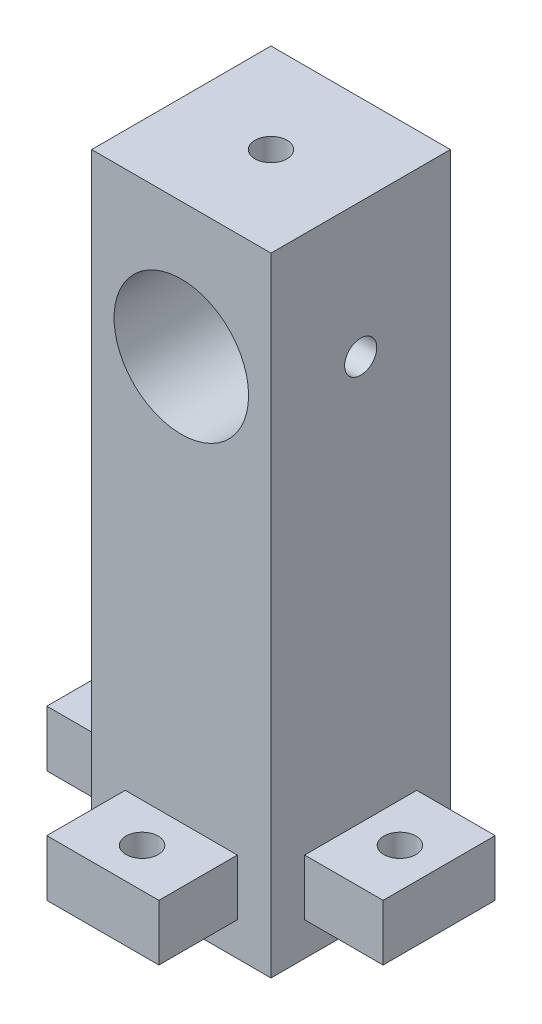
from build123d import *

# Parameters (mm, degrees)
CROQUIS1_W              = 16
CROQUIS1_H              = 16
SALIENTE_EXTRUIR1_DEPTH = 56
CORTAR_EXTRUIR1_REACH   = 18
CROQUIS2_R              = 6
CROQUIS3_R              = 1.435
CORTAR_EXTRUIR2_DEPTH   = 16
CORTAR_EXTRUIR3_REACH   = 58
CROQUIS4_R              = 1.435
CROQUIS5_W              = 10
CROQUIS5_H              = 5
SALIENTE_EXTRUIR2_DEPTH = 7
CROQUIS6_R              = 1.435
CORTAR_EXTRUIR4_DEPTH   = 5
CROQUIS7_W              = 10
CROQUIS7_H              = 5
SALIENTE_EXTRUIR3_DEPTH = 7
CORTAR_EXTRUIR5_REACH   = 10
CROQUIS8_R              = 1.435


with BuildPart() as part:
    # Croquis1 → Saliente-Extruir1 (new body)
    with BuildSketch(Plane(origin=(0, 0, 0), x_dir=(1, 0, 0), z_dir=(0, 1, 0))):
        Rectangle(CROQUIS1_W, CROQUIS1_H)
    extrude(amount=SALIENTE_EXTRUIR1_DEPTH)

    # Croquis2 → Cortar-Extruir1 (cut, up to next)
    with BuildSketch(Plane.XY.offset(8), mode=Mode.PRIVATE) as cortar_extruir1_sk1:
        with Locations((0, 44)):
            Circle(CROQUIS2_R)
    cortar_extruir1_tool1 = extrude(cortar_extruir1_sk1.sketch, amount=-CORTAR_EXTRUIR1_REACH, mode=Mode.PRIVATE) & part.part
    add(cortar_extruir1_tool1.solids().sort_by_distance((0, 44, 8))[0], mode=Mode.SUBTRACT)

    # Croquis3 → Cortar-Extruir2 (cut)
    with BuildSketch(Plane(origin=(8, 0, 0), x_dir=(0, 0, -1), z_dir=(1, 0, 0))):
        with Locations((0, 44)):
            Circle(CROQUIS3_R)
    extrude(amount=-CORTAR_EXTRUIR2_DEPTH, mode=Mode.SUBTRACT)

    # Croquis4 → Cortar-Extruir3 (cut, up to next)
    with BuildSketch(Plane(origin=(0, 56, 0), x_dir=(1, 0, 0), z_dir=(0, 1, 0)), mode=Mode.PRIVATE) as cortar_extruir3_sk1:
        Circle(CROQUIS4_R)
    cortar_extruir3_tool1 = extrude(cortar_extruir3_sk1.sketch, amount=-CORTAR_EXTRUIR3_REACH, mode=Mode.PRIVATE) & part.part
    add(cortar_extruir3_tool1.solids().sort_by_distance((0, 56, 0))[0], mode=Mode.SUBTRACT)

    # Croquis5 → Saliente-Extruir2 (add)
    with BuildSketch(Plane.ZY.offset(8)):
        with Locations((0, 5.5)):
            Rectangle(CROQUIS5_W, CROQUIS5_H)
    saliente_extruir2 = extrude(amount=SALIENTE_EXTRUIR2_DEPTH)

    # Croquis6 → Cortar-Extruir4 (cut)
    with BuildSketch(Plane(origin=(0, 8, 0), x_dir=(1, 0, 0), z_dir=(0, 1, 0))):
        with Locations((-11.5, 0)):
            Circle(CROQUIS6_R)
    cortar_extruir4 = extrude(amount=-CORTAR_EXTRUIR4_DEPTH, mode=Mode.SUBTRACT)

    # Simetría1: Saliente-Extruir2, Cortar-Extruir4 across plane
    add(saliente_extruir2.mirror(Plane(origin=(0, 0, 0), x_dir=(0, 0, 1), z_dir=(1, 0, 0))))
    add(cortar_extruir4.mirror(Plane(origin=(0, 0, 0), x_dir=(0, 0, 1), z_dir=(1, 0, 0))), mode=Mode.SUBTRACT)

    # Croquis7 → Saliente-Extruir3 (add)
    with BuildSketch(Plane.XY.offset(8)):
        with Locations((0, 5.5)):
            Rectangle(CROQUIS7_W, CROQUIS7_H)
    extrude(amount=SALIENTE_EXTRUIR3_DEPTH)

    # Croquis8 → Cortar-Extruir5 (cut, up to next)
    with BuildSketch(Plane(origin=(0, 8, 0), x_dir=(1, 0, 0), z_dir=(0, 1, 0)), mode=Mode.PRIVATE) as cortar_extruir5_sk1:
        with Locations((0, -11.5)):
            Circle(CROQUIS8_R)
    cortar_extruir5_tool1 = extrude(cortar_extruir5_sk1.sketch, amount=-CORTAR_EXTRUIR5_REACH, mode=Mode.PRIVATE) & part.part
    add(cortar_extruir5_tool1.solids().sort_by_distance((0, 8, 11.5))[0], mode=Mode.SUBTRACT)


solid = part.part
